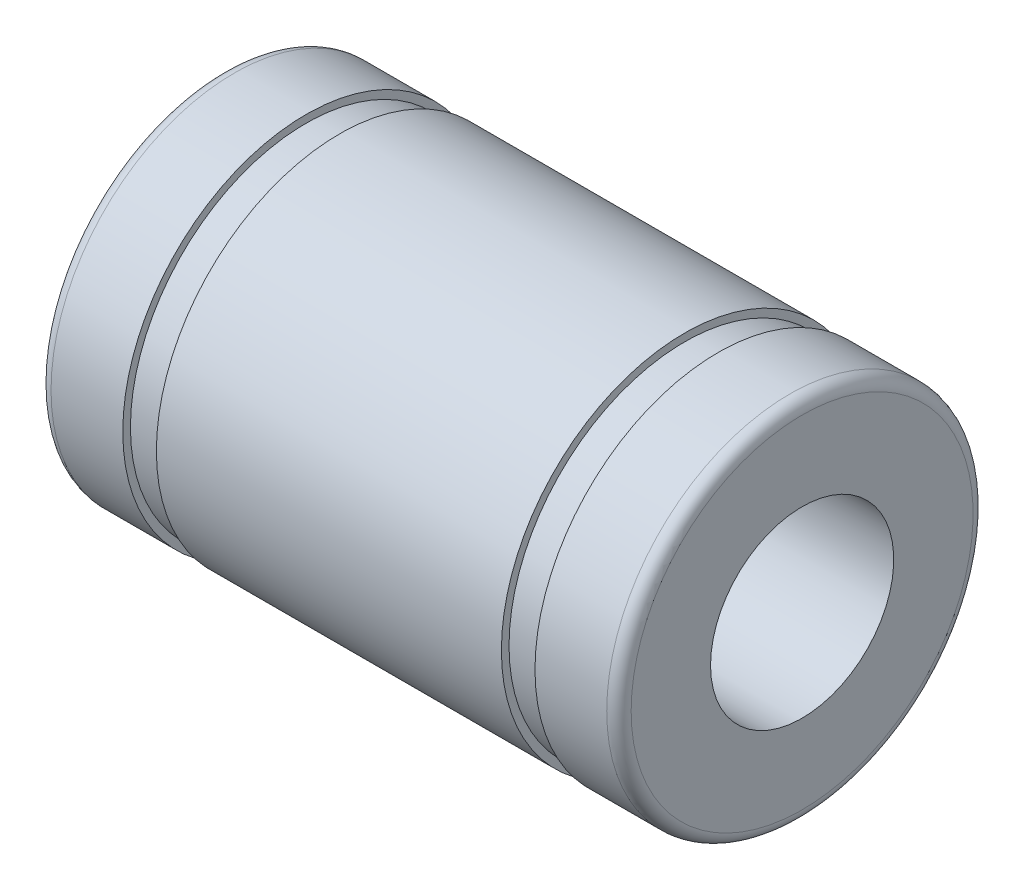
from build123d import *


with BuildPart() as part:
    # Sketch1 → Revolve1 (revolve)
    with BuildSketch(Plane.XY):
        with BuildLine():
            Line((0, 5.6), (0, 3))
            Line((0, 3), (19, 3))
            Line((19, 3), (19, 5.6))
            ThreePointArc((19, 5.6), (18.882842712, 5.882842712), (18.6, 6))
            Line((18.6, 6), (16.25, 6))
            Line((16.25, 6), (16.25, 5.75))
            Line((16.25, 5.75), (15.15, 5.75))
            Line((15.15, 5.75), (15.15, 6))
            Line((15.15, 6), (3.85, 6))
            Line((3.85, 6), (3.85, 5.75))
            Line((3.85, 5.75), (2.75, 5.75))
            Line((2.75, 5.75), (2.75, 6))
            Line((2.75, 6), (0.4, 6))
            ThreePointArc((0.4, 6), (0.117157288, 5.882842712), (0, 5.6))
        make_face()
    revolve(axis=Axis((19, 0, 0), (-1, 0, 0)))


solid = part.part
